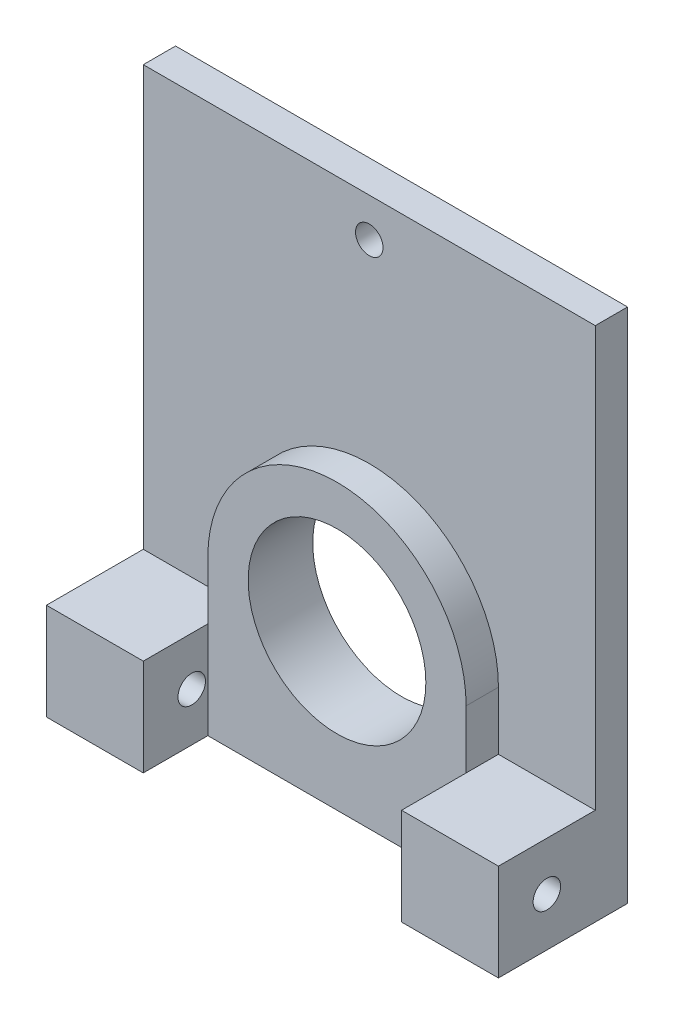
from build123d import *

# Parameters (mm, degrees)
SKETCH1_W                           = 44.45
SKETCH1_H                           = 50.8
BOSS_EXTRUDE1_DEPTH                 = 3.175
BOSS_EXTRUDE2_DEPTH                 = 3.175
SKETCH3_W                           = 9.525
SKETCH3_H                           = 9.525
BOSS_EXTRUDE3_DEPTH                 = 9.525
SKETCH4_R                           = 8.7376
CUT_EXTRUDE1_DEPTH                  = 7.35
F_6_32_TAPPED_HOLE1_D               = 2.7051
F_6_32_TAPPED_HOLE1_DEPTH           = 9.525
F_6_32_TAPPED_HOLE1_ON_FACE_2_D     = 2.7051
F_6_32_TAPPED_HOLE1_ON_FACE_2_DEPTH = 9.525
F_6_32_TAPPED_HOLE1_ON_FACE_3_D     = 2.7051
F_6_32_TAPPED_HOLE1_ON_FACE_3_DEPTH = 9.525


with BuildPart() as part:
    # Sketch1 → Boss-Extrude1 (new body)
    with BuildSketch(Plane.XY):
        Rectangle(SKETCH1_W, SKETCH1_H)
    extrude(amount=BOSS_EXTRUDE1_DEPTH)

    # Sketch2 → Boss-Extrude2 (add)
    with BuildSketch(Plane.XY.offset(3.175)):
        with BuildLine():
            Line((-12.7, -10.16), (-12.7, -25.4))
            Line((-12.7, -25.4), (12.7, -25.4))
            Line((12.7, -25.4), (12.7, -10.16))
            ThreePointArc((12.7, -10.16), (0, 2.54), (-12.7, -10.16))
        make_face()
    extrude(amount=BOSS_EXTRUDE2_DEPTH)

    # Sketch3 → Boss-Extrude3 (add)
    with BuildSketch(Plane.XY.offset(3.175)):
        with Locations((-17.4625, -20.6375)):
            Rectangle(SKETCH3_W, SKETCH3_H)
        with Locations((17.4625, -20.6375)):
            Rectangle(SKETCH3_W, SKETCH3_H)
    extrude(amount=BOSS_EXTRUDE3_DEPTH)

    # Sketch4 → Cut-Extrude1 (cut, through all)
    with BuildSketch(Plane.XY.offset(6.35)):
        with Locations((0, -10.16)):
            Circle(SKETCH4_R)
    extrude(amount=-CUT_EXTRUDE1_DEPTH, mode=Mode.SUBTRACT)

    # #6-32 Tapped Hole1
    with Locations(Plane(origin=(22.225, -20.6375, 7.9375), x_dir=(0, 1, 0), z_dir=(1, 0, 0))):
        with Locations((0, 0)):
            Hole(F_6_32_TAPPED_HOLE1_D / 2, depth=F_6_32_TAPPED_HOLE1_DEPTH)

    # #6-32 Tapped Hole1 on face 2
    with Locations(Plane(origin=(-22.225, -20.6375, 7.9375), x_dir=(0, 0, -1), z_dir=(-1, 0, 0))):
        with Locations((0, 0)):
            Hole(F_6_32_TAPPED_HOLE1_ON_FACE_2_D / 2, depth=F_6_32_TAPPED_HOLE1_ON_FACE_2_DEPTH)

    # #6-32 Tapped Hole1 on face 3
    with Locations(Plane(origin=(0, 21.59, 3.175), x_dir=(1, 0, 0), z_dir=(0, 0, 1))):
        with Locations((0, 0)):
            Hole(F_6_32_TAPPED_HOLE1_ON_FACE_3_D / 2, depth=F_6_32_TAPPED_HOLE1_ON_FACE_3_DEPTH)


solid = part.part
